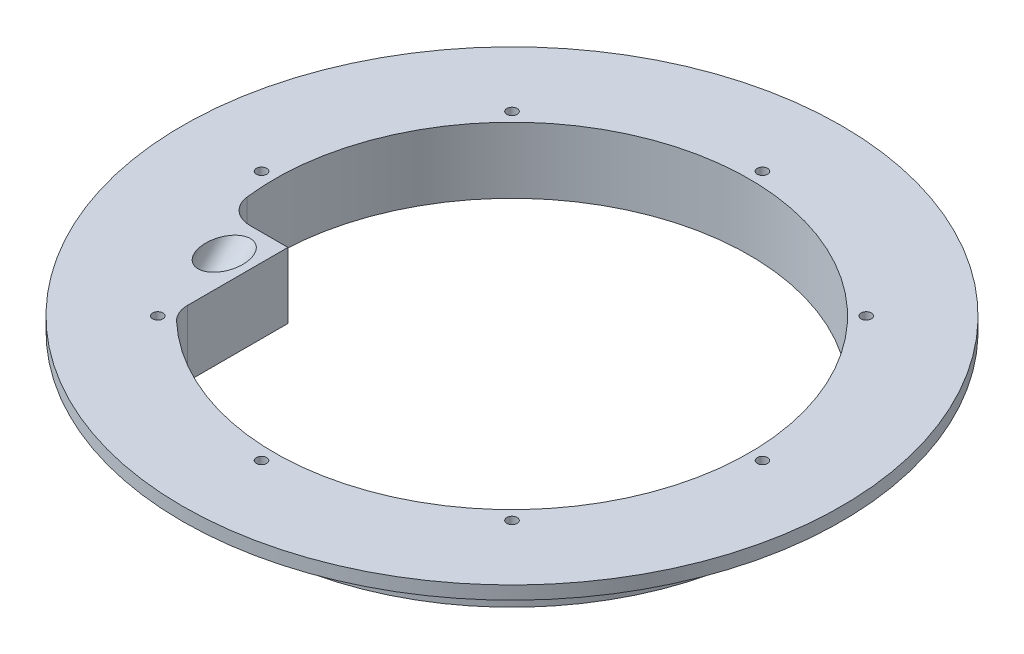
from build123d import *

# Parameters (mm, degrees)
SKETCH7_R                         = 158.75
SKETCH7_R_2                       = 127
BOSS_EXTRUDE2_DEPTH               = 6.35
SKETCH7_3_R                       = 127
BOSS_EXTRUDE3_DEPTH               = 31.75
PIPE_TAP_DRILL_FOR_1_2_TAP2_D     = 17.8562
PIPE_TAP_DRILL_FOR_1_2_TAP2_DEPTH = 31.75
PIPE_TAP_DRILL_FOR_1_2_TAP2_TIP   = 5.364543693
F_1_2_0_5_DIAMETER_HOLE3_D        = 12.7
F_1_2_0_5_DIAMETER_HOLE3_DEPTH    = 62.23
F_1_2_0_5_DIAMETER_HOLE3_TIP      = 3.815464931
F_1_2_0_5_DIAMETER_HOLE4_D        = 12.7
F_1_2_0_5_DIAMETER_HOLE4_DEPTH    = 39.37
F_1_2_0_5_DIAMETER_HOLE4_TIP      = 3.815464931
F_10_CLEARANCE_HOLE1_D            = 4.9784
CIRPATTERN1_COUNT                 = 8


with BuildPart() as part:
    # Sketch7 → Boss-Extrude2 (new body)
    with BuildSketch(Plane(origin=(0, 0, 0), x_dir=(1, 0, 0), z_dir=(0, 1, 0))):
        Circle(SKETCH7_R)
        Circle(SKETCH7_R_2, mode=Mode.SUBTRACT)
    extrude(amount=-BOSS_EXTRUDE2_DEPTH)

    # Sketch7_3 → Boss-Extrude3 (add)
    with BuildSketch(Plane(origin=(0, 0, 0), x_dir=(1, 0, 0), z_dir=(0, 1, 0))):
        Circle(SKETCH7_3_R)
        with BuildLine():
            ThreePointArc((-100.803124952, -25.4), (-109.203385364, -22.225), (-113.403515571, -14.2875))
            ThreePointArc((-113.403515571, -14.2875), (101.95581504, 51.66722152), (-78.58125, -83.002874338))
            ThreePointArc((-78.58125, -83.002874338), (-81.5156949, -78.800448531), (-82.55, -73.780332745))
            Line((-82.55, -73.780332745), (-82.55, -25.4))
            Line((-82.55, -25.4), (-100.803124952, -25.4))
        make_face(mode=Mode.SUBTRACT)
    extrude(amount=-BOSS_EXTRUDE3_DEPTH)

    # Pipe Tap Drill for 1_2 Tap2
    with Locations(Plane(origin=(0, -12.7, 12.7), x_dir=(1, 0, 0), z_dir=(0, 0.7071067811865488, -0.7071067811865464))):
        with Locations((-95.25, -30.660512242)):
            Hole(PIPE_TAP_DRILL_FOR_1_2_TAP2_D / 2, depth=PIPE_TAP_DRILL_FOR_1_2_TAP2_DEPTH)
            with Locations((0, 0, -(PIPE_TAP_DRILL_FOR_1_2_TAP2_DEPTH + PIPE_TAP_DRILL_FOR_1_2_TAP2_TIP / 2))):  # 118° drill point
                Cone(0, PIPE_TAP_DRILL_FOR_1_2_TAP2_D / 2, PIPE_TAP_DRILL_FOR_1_2_TAP2_TIP, mode=Mode.SUBTRACT)

    # 1_2 _0.5_ Diameter Hole3
    with Locations(Plane.XY.offset(127)):
        with Locations((-95.25, -19.05)):
            Hole(F_1_2_0_5_DIAMETER_HOLE3_D / 2, depth=F_1_2_0_5_DIAMETER_HOLE3_DEPTH)
            with Locations((0, 0, -(F_1_2_0_5_DIAMETER_HOLE3_DEPTH + F_1_2_0_5_DIAMETER_HOLE3_TIP / 2))):  # 118° drill point
                Cone(0, F_1_2_0_5_DIAMETER_HOLE3_D / 2, F_1_2_0_5_DIAMETER_HOLE3_TIP, mode=Mode.SUBTRACT)

    # 1_2 _0.5_ Diameter Hole4
    with Locations(Plane(origin=(0, -12.7, 12.7), x_dir=(1, 0, 0), z_dir=(0, 0.7071067811865488, -0.7071067811865464))):
        with Locations((-95.25, -30.660512242)):
            Hole(F_1_2_0_5_DIAMETER_HOLE4_D / 2, depth=F_1_2_0_5_DIAMETER_HOLE4_DEPTH)
            with Locations((0, 0, -(F_1_2_0_5_DIAMETER_HOLE4_DEPTH + F_1_2_0_5_DIAMETER_HOLE4_TIP / 2))):  # 118° drill point
                Cone(0, F_1_2_0_5_DIAMETER_HOLE4_D / 2, F_1_2_0_5_DIAMETER_HOLE4_TIP, mode=Mode.SUBTRACT)

    # 10 Clearance Hole1 (through all)
    with Locations(Plane(origin=(0, 0, 0), x_dir=(1, 0, 0), z_dir=(0, 1, 0))):
        with Locations((0, -120.65)):
            f_10_clearance_hole1 = Hole(F_10_CLEARANCE_HOLE1_D / 2)

    # CirPattern1: 10 Clearance Hole1 ×8 about axis
    cirpattern1_axis = Axis((0, -31.75, 0), (0, 1, 0))
    for i in range(1, CIRPATTERN1_COUNT):
        add(f_10_clearance_hole1.rotate(cirpattern1_axis, i * 360 / CIRPATTERN1_COUNT), mode=Mode.SUBTRACT)


solid = part.part
